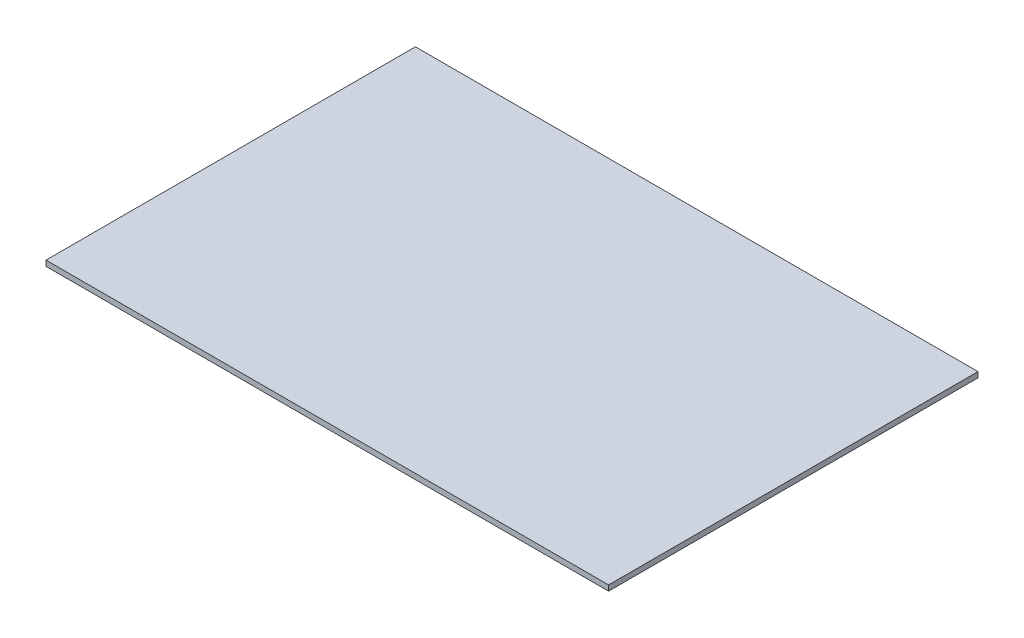
from build123d import *

# Parameters (mm, degrees)
SKETCH1_W           = 300
SKETCH1_H           = 197
BOSS_EXTRUDE1_DEPTH = 2.9


with BuildPart() as part:
    # Sketch1 → Boss-Extrude1 (new body)
    with BuildSketch(Plane(origin=(0, 0, 0), x_dir=(1, 0, 0), z_dir=(0, 1, 0))):
        Rectangle(SKETCH1_W, SKETCH1_H)
    extrude(amount=BOSS_EXTRUDE1_DEPTH)


solid = part.part
